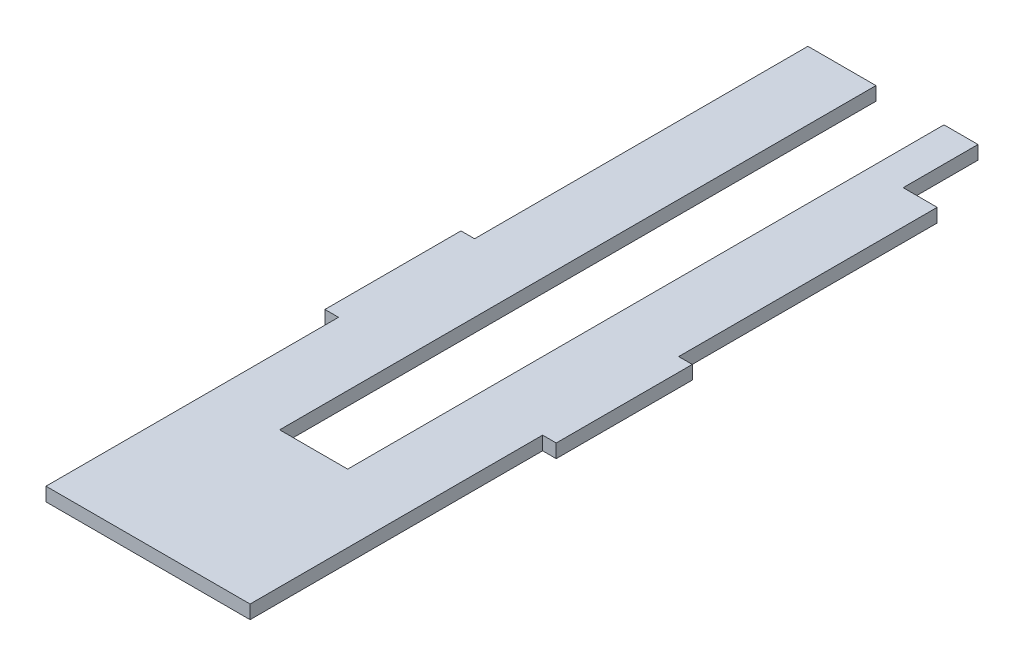
from build123d import *

# Parameters (mm, degrees)
BOSS_EXTRUDE1_DEPTH = 10
SKETCH2_W           = 25
SKETCH2_H           = 55
CUT_EXTRUDE1_DEPTH  = 10


with BuildPart() as part:
    # Sketch1 → Boss-Extrude1 (new body)
    with BuildSketch(Plane(origin=(0, 0, 0), x_dir=(1, 0, 0), z_dir=(0, 1, 0))):
        Polygon((-75, 215), (-75, 0), (75, 0), (75, 215), (85, 215), (85, 315), (75, 315), (75, 560), (25, 560), (25, 121.727049474), (-25, 121.727049474), (-25, 560), (-75, 560), (-75, 315), (-85, 315), (-85, 215), align=None)
    extrude(amount=BOSS_EXTRUDE1_DEPTH)

    # Sketch2 → Cut-Extrude1 (cut)
    with BuildSketch(Plane(origin=(0, 10, 0), x_dir=(1, 0, 0), z_dir=(0, 1, 0))):
        with Locations((62.5, 532.5)):
            Rectangle(SKETCH2_W, SKETCH2_H)
    extrude(amount=-CUT_EXTRUDE1_DEPTH, mode=Mode.SUBTRACT)


solid = part.part
